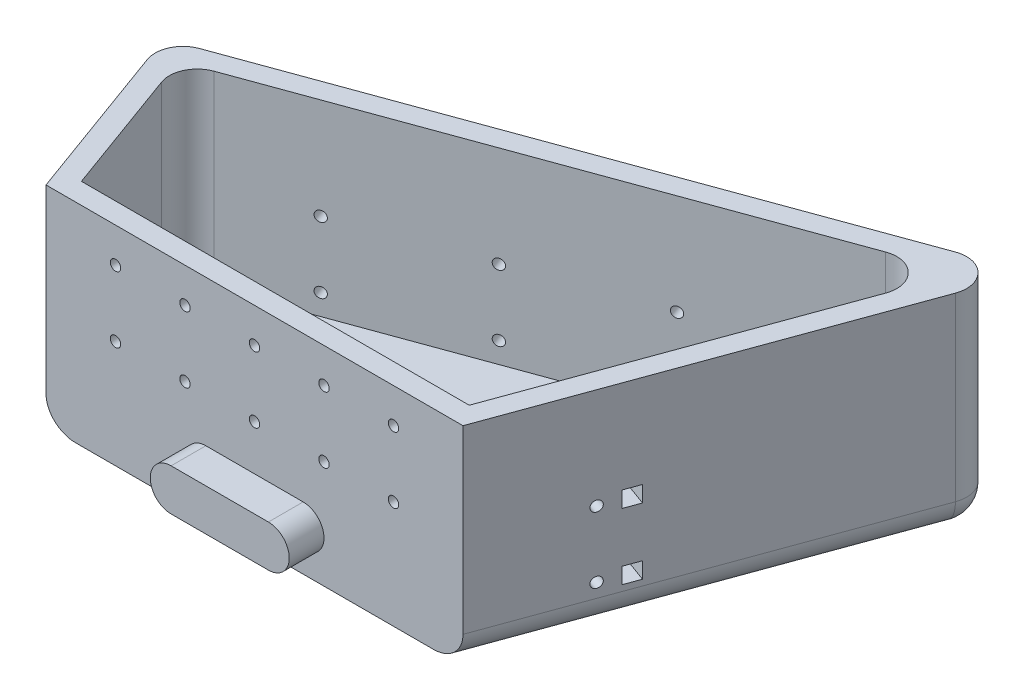
from build123d import *

# Parameters (mm, degrees)
BOSS_EXTRUDE1_DEPTH = 30
BOSS_EXTRUDE2_DEPTH = 3
FILLET1_R           = 4
SKETCH4_R           = 0.75
CUT_EXTRUDE1_DEPTH  = 3
SKETCH9_R           = 0.75
CUT_EXTRUDE4_DEPTH  = 3
SKETCH6_R           = 0.75
CUT_EXTRUDE3_DEPTH  = 3
BOSS_EXTRUDE3_DEPTH = 5
SKETCH10_W          = 2.3
SKETCH10_H          = 2.3
CUT_EXTRUDE5_DEPTH  = 3


with BuildPart() as part:
    # Sketch1 → Boss-Extrude1 (new body)
    with BuildSketch(Plane(origin=(0, 0, 0), x_dir=(1, 0, 0), z_dir=(0, 1, 0))):
        Polygon((14.623899198, -62.06566226), (4.913523379, -35.386623963), (96.462113254, -2.06566226), (74.623899198, -62.06566226), align=None)
        Polygon((16.724521813, -59.06566226), (8.758661672, -37.179641396), (91.442641699, -7.085133815), (72.523276583, -59.06566226), align=None, mode=Mode.SUBTRACT)
    extrude(amount=BOSS_EXTRUDE1_DEPTH)

    # Sketch3 → Boss-Extrude2 (add)
    with BuildSketch(Plane(origin=(0, 0, 0), x_dir=(1, 0, 0), z_dir=(0, 1, 0))):
        Polygon((8.758661672, -37.179641396), (16.724521813, -59.06566226), (72.523276583, -59.06566226), (91.442641699, -7.085133815), align=None)
    extrude(amount=BOSS_EXTRUDE2_DEPTH)

    # Fillet1
    fillet1_edges = [part.edges().sort_by_distance(p)[0] for p in [
        (91.442641699, 16.5, 7.085133815),
        (8.758661672, 16.5, 37.179641396),
        (9.768711289, 0, 48.726143111),
        (50.687818317, 0, 18.726143111),
        (85.543006226, 0, 32.06566226),
        (4.913523379, 15, 35.386623963),
        (96.462113254, 15, 2.06566226),
    ]]
    fillet(fillet1_edges, radius=FILLET1_R)

    # Sketch4 → Cut-Extrude1 (cut)
    with BuildSketch(Plane(origin=(11.947814765, 0, 32.826351279), x_dir=(-0.939692621, 0, 0.342020143), z_dir=(-0.342020143, 0, -0.939692621))):
        with Locations((-71.514263462, 15.5)):
            Circle(SKETCH4_R)
        with Locations((-51.514263462, 15.5)):
            Circle(SKETCH4_R)
        with Locations((-31.514263462, 15.5)):
            Circle(SKETCH4_R)
        with Locations((-11.514263462, 15.5)):
            Circle(SKETCH4_R)
        with Locations((-11.514263462, 6)):
            Circle(SKETCH4_R)
        with Locations((-31.514263462, 6)):
            Circle(SKETCH4_R)
        with Locations((-51.514263462, 6)):
            Circle(SKETCH4_R)
        with Locations((-71.514263462, 6)):
            Circle(SKETCH4_R)
    extrude(amount=-CUT_EXTRUDE1_DEPTH, mode=Mode.SUBTRACT)

    # Sketch9 → Cut-Extrude4 (cut)
    with BuildSketch(Plane(origin=(85.842080595, 0, 31.243962184), x_dir=(0.342020143, 0, -0.939692621), z_dir=(0.939692621, 0, 0.342020143))):
        with Locations((-17.79976813, 15.5)):
            Circle(SKETCH9_R)
        with Locations((-17.79976813, 6)):
            Circle(SKETCH9_R)
    extrude(amount=-CUT_EXTRUDE4_DEPTH, mode=Mode.SUBTRACT)

    # Sketch6 → Cut-Extrude3 (cut)
    with BuildSketch(Plane.XY.offset(62.06566226)):
        with Locations((34.623899198, 25)):
            Circle(SKETCH6_R)
        with Locations((44.623899198, 25)):
            Circle(SKETCH6_R)
        with Locations((54.623899198, 25)):
            Circle(SKETCH6_R)
        with Locations((64.623899198, 25)):
            Circle(SKETCH6_R)
        with Locations((34.623899198, 15.5)):
            Circle(SKETCH6_R)
        with Locations((44.623899198, 15.5)):
            Circle(SKETCH6_R)
        with Locations((54.623899198, 15.5)):
            Circle(SKETCH6_R)
        with Locations((64.623899198, 15.5)):
            Circle(SKETCH6_R)
        with Locations((24.623899198, 25)):
            Circle(SKETCH6_R)
        with Locations((24.623899198, 15.5)):
            Circle(SKETCH6_R)
    extrude(amount=-CUT_EXTRUDE3_DEPTH, mode=Mode.SUBTRACT)

    # Sketch7 → Boss-Extrude3 (add)
    with BuildSketch(Plane.XY.offset(62.06566226)):
        with BuildLine():
            Line((37.623899198, 9), (51.623899198, 9))
            ThreePointArc((51.623899198, 9), (54.623899198, 6), (51.623899198, 3))
            Line((51.623899198, 3), (37.623899198, 3))
            ThreePointArc((37.623899198, 3), (34.623899198, 6), (37.623899198, 9))
        make_face()
    extrude(amount=BOSS_EXTRUDE3_DEPTH)

    # Sketch10 → Cut-Extrude5 (cut)
    with BuildSketch(Plane(origin=(85.842080595, 0, 31.243962184), x_dir=(0.342020143, 0, -0.939692621), z_dir=(0.939692621, 0, 0.342020143))):
        with Locations((-13.79976813, 15.5)):
            Rectangle(SKETCH10_W, SKETCH10_H)
        with Locations((-13.79976813, 6)):
            Rectangle(SKETCH10_W, SKETCH10_H)
    extrude(amount=-CUT_EXTRUDE5_DEPTH, mode=Mode.SUBTRACT)


solid = part.part
